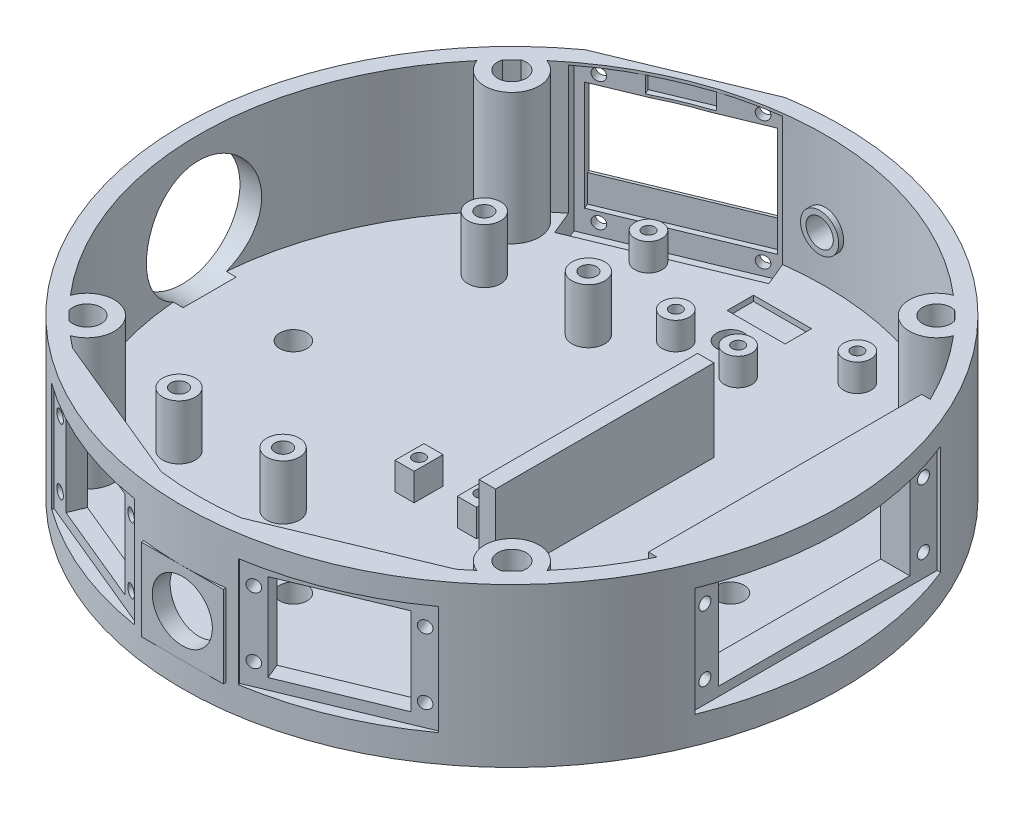
from build123d import *

# Parameters (mm, degrees)
SKETCH1_R                = 60.325
BOSS_EXTRUDE1_DEPTH      = 5
SKETCH3_R                = 60.325
SKETCH3_R_2              = 57.325
BOSS_EXTRUDE3_DEPTH      = 24
BOSS_EXTRUDE13_DEPTH     = 2
SKETCH7_R                = 5.5
CUT_EXTRUDE1_DEPTH       = 5
SKETCH15_R               = 12.5
BOSS_EXTRUDE15_DEPTH     = 3
SKETCH16_R               = 10.55
CUT_EXTRUDE9_DEPTH       = 5
SKETCH17_R               = 2.5000000000000018
SKETCH17_R_2             = 2.500000000000002
SKETCH17_R_3             = 2.5000000000000004
CUT_EXTRUDE10_DEPTH      = 5
SKETCH20_W               = 10.617189631650703
SKETCH20_H               = 4.842928603910877
CUT_EXTRUDE13_DEPTH      = 1
SKETCH26_W               = 50
SKETCH26_H               = 24
BOSS_EXTRUDE46_DEPTH     = 10
SKETCH27_W               = 45
SKETCH27_H               = 20.000000000000004
CUT_EXTRUDE15_DEPTH      = 5
SKETCH29_R               = 1.0999999999999992
CUT_EXTRUDE17_DEPTH      = 10
CUT_EXTRUDE18_DEPTH      = 20
BOSS_EXTRUDE47_DEPTH     = 24
CUT_EXTRUDE19_START      = -30
CUT_EXTRUDE19_DEPTH      = 30
SKETCH31_R               = 3.0000000000000018
SKETCH31_R_2             = 3.0000000000000004
BOSS_EXTRUDE48_DEPTH     = 10
SKETCH32_R               = 1.5000000000000024
SKETCH32_R_2             = 1.5000000000000042
CUT_EXTRUDE20_DEPTH      = 5
SKETCH33_R               = 2.500000000000004
SKETCH33_R_2             = 2.4999999999999973
BOSS_EXTRUDE49_DEPTH     = 5
SKETCH34_R               = 1.100000000000003
SKETCH34_R_2             = 1.100000000000001
SKETCH34_R_3             = 1.1
SKETCH34_R_4             = 1.0999999999999983
CUT_EXTRUDE21_DEPTH      = 5
BOSS_EXTRUDE50_DEPTH     = 15
BOSS_EXTRUDE51_DEPTH     = 2
CUT_EXTRUDE25_DEPTH      = 2
CUT_EXTRUDE26_DEPTH      = 12
SKETCH41_R               = 1.0999999999999992
SKETCH41_R_2             = 1.100000000000001
CUT_EXTRUDE27_DEPTH      = 12
CUT_EXTRUDE28_DEPTH      = 4
CUT_EXTRUDE28_DEPTH_BACK = 2.5
SKETCH44_R               = 2.499999999999999
SKETCH44_R_2             = 2.5000000000000027
BOSS_EXTRUDE52_DEPTH     = 5
SKETCH45_R               = 1.0999999999999983
SKETCH45_R_2             = 1.0999999999999992
CUT_EXTRUDE29_DEPTH      = 5
CUT_EXTRUDE30_DEPTH      = 5
SKETCH47_R               = 1.100000000000001
CUT_EXTRUDE31_DEPTH      = 3
CUT_EXTRUDE32_DEPTH      = 5
SKETCH49_W               = 27
SKETCH49_H               = 5
CUT_EXTRUDE33_DEPTH      = 1
SKETCH52_R               = 3.499999999999999
BOSS_EXTRUDE54_DEPTH     = 4
SKETCH53_R               = 2.500000000000001
CUT_EXTRUDE34_DEPTH      = 4


with BuildPart() as part:
    # Sketch1 → Boss-Extrude1 (new body)
    with BuildSketch(Plane(origin=(0, 0, 0), x_dir=(1, 0, 0), z_dir=(0, 1, 0))):
        Circle(SKETCH1_R)
    extrude(amount=BOSS_EXTRUDE1_DEPTH)

    # Sketch3 → Boss-Extrude3 (add)
    with BuildSketch(Plane(origin=(0, 5, 0), x_dir=(1, 0, 0), z_dir=(0, 1, 0))):
        Circle(SKETCH3_R)
        Circle(SKETCH3_R_2, mode=Mode.SUBTRACT)
    extrude(amount=BOSS_EXTRUDE3_DEPTH)

    # Sketch6 → Boss-Extrude13 (add)
    with BuildSketch(Plane.XY.offset(60.325)):
        Polygon((-7.5, 19.5), (7.5, 19.5), (7.5000000000000036, 4.500000000000001), (-7.4999999999999964, 4.500000000000001), align=None)
    extrude(amount=-BOSS_EXTRUDE13_DEPTH)

    # Sketch7 → Cut-Extrude1 (cut)
    with BuildSketch(Plane.XY.offset(60.325)):
        with Locations((0, 12.313384582393407)):
            Circle(SKETCH7_R)
    extrude(amount=-CUT_EXTRUDE1_DEPTH, mode=Mode.SUBTRACT)

    # Sketch15 → Boss-Extrude15 (add)
    with BuildSketch(Plane.ZY.offset(60.325)):
        with Locations((0, 14.079498945802262)):
            Circle(SKETCH15_R)
    extrude(amount=-BOSS_EXTRUDE15_DEPTH)

    # Sketch16 → Cut-Extrude9 (cut)
    with BuildSketch(Plane.ZY.offset(60.325)):
        with Locations((0, 14.367365331349822)):
            Circle(SKETCH16_R)
    extrude(amount=-CUT_EXTRUDE9_DEPTH, mode=Mode.SUBTRACT)

    # Sketch17 → Cut-Extrude10 (cut)
    with BuildSketch(Plane(origin=(0, 5, 0), x_dir=(1, 0, 0), z_dir=(0, 1, 0))):
        with Locations((0, 40)):
            Circle(SKETCH17_R)
        with Locations((40, 0)):
            Circle(SKETCH17_R_2)
        with Locations((0, -40)):
            Circle(SKETCH17_R_3)
        with Locations((-40, 0)):
            Circle(SKETCH17_R_2)
    extrude(amount=-CUT_EXTRUDE10_DEPTH, mode=Mode.SUBTRACT)

    # Sketch20 → Cut-Extrude13 (cut)
    with BuildSketch(Plane(origin=(0, 5, 0), x_dir=(1, 0, 0), z_dir=(0, 1, 0))):
        with Locations((0.20330529432061706, 46.91179778863133)):
            Rectangle(SKETCH20_W, SKETCH20_H)
    extrude(amount=-CUT_EXTRUDE13_DEPTH, mode=Mode.SUBTRACT)

    # Sketch26 → Boss-Extrude46 (add)
    with BuildSketch(Plane(origin=(50, 0, 0), x_dir=(0, 0, -1), z_dir=(1, 0, 0))):
        with Locations((3.55e-15, 17.000000000000004)):
            Rectangle(SKETCH26_W, SKETCH26_H)
    extrude(amount=BOSS_EXTRUDE46_DEPTH)

    # Sketch27 → Cut-Extrude15 (cut)
    with BuildSketch(Plane(origin=(60.325, 0, 0), x_dir=(0, 0, -1), z_dir=(1, 0, 0))):
        with Locations((7.11e-15, 15.000000000000002)):
            Rectangle(SKETCH27_W, SKETCH27_H)
    extrude(amount=-CUT_EXTRUDE15_DEPTH, mode=Mode.SUBTRACT)

    # Sketch29 → Cut-Extrude17 (cut)
    with BuildSketch(Plane(origin=(55.325, 0, 0), x_dir=(0, 0, -1), z_dir=(1, 0, 0))):
        with Locations((-19.999999999999986, 20.999999999999996)):
            Circle(SKETCH29_R)
        with Locations((-19.999999999999986, 9)):
            Circle(SKETCH29_R)
        with Locations((20.000000000000018, 20.999999999999996)):
            Circle(SKETCH29_R)
        with Locations((20.000000000000014, 9.151874819132662)):
            Circle(SKETCH29_R)
    extrude(amount=-CUT_EXTRUDE17_DEPTH, mode=Mode.SUBTRACT)

    # Sketch28 → Cut-Extrude18 (cut)
    with BuildSketch(Plane(origin=(60.325, 0, 0), x_dir=(0, 0, -1), z_dir=(1, 0, 0))):
        Polygon((-17.499999999999996, 23.348125180867335), (17.500000000000004, 23.348125180867342), (17.500000000000007, 6.6518748191326615), (-17.499999999999996, 6.651874819132655), align=None)
    extrude(amount=-CUT_EXTRUDE18_DEPTH, mode=Mode.SUBTRACT)

    # Sketch5 → Boss-Extrude47 (add)
    with BuildSketch(Plane(origin=(0, 5, 0), x_dir=(1, 0, 0), z_dir=(0, 1, 0))):
        with BuildLine():
            ThreePointArc((-43.60197437500719, 37.21590326192842), (-35.35533905932737, 35.35533905932737), (-37.21590326192842, 43.60197437500719))
            ThreePointArc((-37.21590326192843, 43.60197437500721), (-38.46725117333861, 42.50207303376248), (-39.68610768350217, 41.366272275048786))
            ThreePointArc((-39.68610768350219, 41.366272275048814), (-37.05239533417509, 37.05239533417509), (-41.366272275048814, 39.6861076835022))
            ThreePointArc((-41.36627227504878, 39.686107683502186), (-42.50207303376247, 38.467251173338624), (-43.6019743750072, 37.21590326192844))
        make_face()
        with BuildLine():
            ThreePointArc((37.21590326192817, 43.601974375007195), (35.35533905932738, 35.355339059327385), (43.601974375007124, 37.21590326192848))
            ThreePointArc((43.60197437500715, 37.215903261928496), (42.50207303376246, 38.46725117333864), (41.36627227504882, 39.68610768350214))
            ThreePointArc((41.36627227504881, 39.68610768350213), (37.05239533417504, 37.05239533417516), (39.68610768350197, 41.36627227504895))
            ThreePointArc((39.68610768350199, 41.36627227504897), (38.46725117333843, 42.502073033762635), (37.21590326192824, 43.601974375007366))
        make_face()
        with BuildLine():
            ThreePointArc((-43.601974375007224, -37.2159032619284), (-42.50207303376248, -38.46725117333861), (-41.36627227504879, -39.68610768350217))
            ThreePointArc((-41.36627227504882, -39.68610768350219), (-37.05239533417508, -37.052395334175095), (-39.68610768350219, -41.36627227504882))
            ThreePointArc((-39.686107683502186, -41.36627227504878), (-38.467251173338624, -42.502073033762464), (-37.215903261928425, -43.60197437500721))
            ThreePointArc((-37.2159032619284, -43.6019743750072), (-35.35533905932736, -35.35533905932738), (-43.60197437500719, -37.21590326192841))
        make_face()
        with BuildLine():
            ThreePointArc((43.60197437500762, -37.21590326192784), (35.35533905932785, -35.35533905932691), (37.21590326192878, -43.601974375006684))
            ThreePointArc((37.21590326192883, -43.60197437500686), (38.467251173339065, -42.50207303376207), (39.68610768350268, -41.3662722750483))
            ThreePointArc((39.68610768350273, -41.36627227504833), (37.05239533417553, -37.05239533417466), (41.3662722750493, -39.68610768350171))
            ThreePointArc((41.36627227504923, -39.6861076835017), (42.50207303376294, -38.46725117333809), (43.60197437500768, -37.215903261927885))
        make_face()
    extrude(amount=BOSS_EXTRUDE47_DEPTH)

    # Sketch30 → Cut-Extrude19 (cut)
    with BuildSketch(Plane(origin=(0, 29, 0), x_dir=(1, 0, 0), z_dir=(0, 1, 0)).offset(CUT_EXTRUDE19_START)):
        with BuildLine():
            Line((51.783140736674326, 30.9453059517236), (68.40972028142612, 30.9453059517236))
            ThreePointArc((68.40972028142612, 30.9453059517236), (75.07900376332695, -0.803108545018857), (67.73210824333012, -32.401594132736065))
            Line((67.73210824333012, -32.401594132736065), (50.88459808878757, -32.401594132736065))
            ThreePointArc((50.88459808878757, -32.401594132736065), (60.31893223906523, -0.8555925075975032), (51.783140736674326, 30.9453059517236))
        make_face()
    extrude(amount=CUT_EXTRUDE19_DEPTH, mode=Mode.SUBTRACT)

    # Sketch31 → Boss-Extrude48 (add)
    with BuildSketch(Plane(origin=(0, 5, 0), x_dir=(1, 0, 0), z_dir=(0, 1, 0))):
        with Locations((-33.05, 28)):
            Circle(SKETCH31_R)
        with Locations((-14.000000000000004, 28)):
            Circle(SKETCH31_R_2)
        with Locations((-13.999999999999996, -27.88)):
            Circle(SKETCH31_R_2)
        with Locations((-33.05, -27.88)):
            Circle(SKETCH31_R)
    extrude(amount=BOSS_EXTRUDE48_DEPTH)

    # Sketch32 → Cut-Extrude20 (cut)
    with BuildSketch(Plane(origin=(0, 15, 0), x_dir=(1, 0, 0), z_dir=(0, 1, 0))):
        with Locations((-13.999999999999996, -27.88)):
            Circle(SKETCH32_R)
        with Locations((-33.05, -27.88)):
            Circle(SKETCH32_R_2)
        with Locations((-33.05, 28)):
            Circle(SKETCH32_R_2)
        with Locations((-14.000000000000004, 28)):
            Circle(SKETCH32_R)
    extrude(amount=-CUT_EXTRUDE20_DEPTH, mode=Mode.SUBTRACT)

    # Sketch33 → Boss-Extrude49 (add)
    with BuildSketch(Plane(origin=(0, 5, 0), x_dir=(1, 0, 0), z_dir=(0, 1, 0))):
        with Locations((-5.000000000000004, 35)):
            Circle(SKETCH33_R)
        with Locations((6.3999989036082425, 35.004999773071894)):
            Circle(SKETCH33_R_2)
        Polygon((-6.750000000000009, -14.647089988643435), (-3.2500000000000084, -14.647089988643431), (-3.2500000000000084, -9.352910011356565), (-6.750000000000009, -9.352910011356565), align=None)
        Polygon((4.649999999999994, -14.647089988643435), (8.149999999999995, -14.647089988643435), (8.149999999999993, -9.352910011356565), (4.649999999999994, -9.352910011356565), align=None)
    extrude(amount=BOSS_EXTRUDE49_DEPTH)

    # Sketch34 → Cut-Extrude21 (cut)
    with BuildSketch(Plane(origin=(0, 10, 0), x_dir=(1, 0, 0), z_dir=(0, 1, 0))):
        with Locations((6.3999989036082425, 35.004999773071894)):
            Circle(SKETCH34_R)
        with Locations((6.399998903608244, -12)):
            Circle(SKETCH34_R_2)
        with Locations((-5.000000000000003, -12)):
            Circle(SKETCH34_R_3)
        with Locations((-5.000000000000004, 35)):
            Circle(SKETCH34_R_4)
    extrude(amount=-CUT_EXTRUDE21_DEPTH, mode=Mode.SUBTRACT)

    # Sketch35 → Boss-Extrude50 (add)
    with BuildSketch(Plane(origin=(0, 5, 0), x_dir=(1, 0, 0), z_dir=(0, 1, 0))):
        Polygon((13.999999999999998, 20), (16.999999999999996, 20), (17, -20), (14.000000000000004, -20), align=None)
    extrude(amount=BOSS_EXTRUDE50_DEPTH)

    # Sketch39 → Boss-Extrude51 (add)
    with BuildSketch(Plane(origin=(21.171960895598467, 0, 51.113635136187), x_dir=(0, -1, 0), z_dir=(0.38268343236508734, 0, 0.9238795325112877))):
        Polygon((-29, 15.014391088551141), (-5.000000000000002, 15.014391088551141), (-4.999999999999997, -14.985608911448859), (-29, -14.985608911448859), align=None)
    boss_extrude51 = extrude(amount=BOSS_EXTRUDE51_DEPTH)

    # Sketch37 → Cut-Extrude25 (cut)
    with BuildSketch(Plane(origin=(23.0853780574239, 0, 55.73303279874344), x_dir=(0, -1, 0), z_dir=(0.38268343236508734, 0, 0.9238795325112877))):
        Polygon((-25, 13.999999999999996), (-5.000000000000001, 13.999999999999996), (-4.999999999999999, -14.000000000000004), (-24.999999999999996, -14.000000000000004), align=None)
    cut_extrude25 = extrude(amount=-CUT_EXTRUDE25_DEPTH, mode=Mode.SUBTRACT)

    # Sketch40 → Cut-Extrude26 (cut)
    with BuildSketch(Plane(origin=(23.0853780574239, 0, 55.73303279874344), x_dir=(0, -1, 0), z_dir=(0.38268343236508734, 0, 0.9238795325112877))):
        Polygon((-23, 9.999999999999996), (-7.000000000000003, 9.999999999999996), (-6.999999999999998, -10.000000000000004), (-22.999999999999996, -10.000000000000004), align=None)
    cut_extrude26 = extrude(amount=-CUT_EXTRUDE26_DEPTH, mode=Mode.SUBTRACT)

    # Sketch41 → Cut-Extrude27 (cut)
    with BuildSketch(Plane(origin=(23.0853780574239, 0, 55.73303279874344), x_dir=(0, -1, 0), z_dir=(0.38268343236508734, 0, 0.9238795325112877))):
        with Locations((-21, 12)):
            Circle(SKETCH41_R)
        with Locations((-9.000000000000002, 12)):
            Circle(SKETCH41_R_2)
        with Locations((-8.999999999999998, -12)):
            Circle(SKETCH41_R_2)
        with Locations((-20.999999999999996, -12)):
            Circle(SKETCH41_R)
    cut_extrude27 = extrude(amount=-CUT_EXTRUDE27_DEPTH, mode=Mode.SUBTRACT)

    # Mirror2: Boss-Extrude51, Cut-Extrude25, Cut-Extrude26, Cut-Extrude27 across plane
    add(boss_extrude51.mirror(Plane(origin=(0, 0, 0), x_dir=(0, 0, 1), z_dir=(1, 0, 0))))
    add(cut_extrude25.mirror(Plane(origin=(0, 0, 0), x_dir=(0, 0, 1), z_dir=(1, 0, 0))), mode=Mode.SUBTRACT)
    add(cut_extrude26.mirror(Plane(origin=(0, 0, 0), x_dir=(0, 0, 1), z_dir=(1, 0, 0))), mode=Mode.SUBTRACT)
    add(cut_extrude27.mirror(Plane(origin=(0, 0, 0), x_dir=(0, 0, 1), z_dir=(1, 0, 0))), mode=Mode.SUBTRACT)

    # Sketch43 → Cut-Extrude28 (cut, two sides: drawn at the far end of the back side and taken through both)
    with BuildSketch(Plane(origin=(-20.923216664561146, 0, -50.51311344005465), x_dir=(0, -1, 0), z_dir=(0.38268343236508734, 0, 0.9238795325112877)).offset(-CUT_EXTRUDE28_DEPTH_BACK)):
        Polygon((-28.5, 15), (-1.0000000000000009, 15), (-0.9999999999999974, -15), (-28.499999999999996, -15), align=None)
    extrude(amount=CUT_EXTRUDE28_DEPTH + CUT_EXTRUDE28_DEPTH_BACK, mode=Mode.SUBTRACT)

    # Sketch44 → Boss-Extrude52 (add)
    with BuildSketch(Plane(origin=(0, 5, 0), x_dir=(1, 0, 0), z_dir=(0, 1, 0))):
        with Locations((-20, 45)):
            Circle(SKETCH44_R)
        with Locations((45, -30)):
            Circle(SKETCH44_R_2)
        with Locations((18.229539652623778, 45)):
            Circle(SKETCH44_R)
        with Locations((18.229539652623778, -32.02717202587299)):
            Circle(SKETCH44_R)
    extrude(amount=BOSS_EXTRUDE52_DEPTH)

    # Sketch45 → Cut-Extrude29 (cut)
    with BuildSketch(Plane(origin=(0, 10, 0), x_dir=(1, 0, 0), z_dir=(0, 1, 0))):
        with Locations((-20, 45)):
            Circle(SKETCH45_R)
        with Locations((18.229539652623778, 45)):
            Circle(SKETCH45_R)
        with Locations((18.229539652623778, -32.02717202587299)):
            Circle(SKETCH45_R)
        with Locations((45, -30)):
            Circle(SKETCH45_R_2)
    extrude(amount=-CUT_EXTRUDE29_DEPTH, mode=Mode.SUBTRACT)

    # Sketch46 → Cut-Extrude30 (cut)
    with BuildSketch(Plane(origin=(-21.879925245473853, 0, -52.82281227133289), x_dir=(0.9238795325112877, 0, -0.38268343236508756), z_dir=(0.38268343236508756, 0, 0.9238795325112877))):
        Polygon((-13.50000000000003, 25), (13.49999999999997, 25), (13.499999999999968, 10), (-13.500000000000028, 10), align=None)
    extrude(amount=-CUT_EXTRUDE30_DEPTH, mode=Mode.SUBTRACT)

    # Sketch47 → Cut-Extrude31 (cut)
    with BuildSketch(Plane(origin=(-21.879925245473853, 0, -52.82281227133289), x_dir=(0.9238795325112877, 0, -0.38268343236508756), z_dir=(0.38268343236508756, 0, 0.9238795325112877))):
        with Locations((11.500000000000005, 26.75)):
            Circle(SKETCH47_R)
        with Locations((-11.499999999999995, 26.75)):
            Circle(SKETCH47_R)
        with Locations((-11.5, 3.25)):
            Circle(SKETCH47_R)
        with Locations((11.500000000000002, 3.25)):
            Circle(SKETCH47_R)
    extrude(amount=-CUT_EXTRUDE31_DEPTH, mode=Mode.SUBTRACT)

    # Sketch48 → Cut-Extrude32 (cut)
    with BuildSketch(Plane(origin=(-22.453950394021497, 0, -54.208631570099804), x_dir=(0, -1, 0), z_dir=(0.38268343236508734, 0, 0.9238795325112877))):
        Polygon((-35, 15), (4.999999999999997, 15), (5.000000000000004, -15), (-34.99999999999999, -15), align=None)
    extrude(amount=-CUT_EXTRUDE32_DEPTH, mode=Mode.SUBTRACT)

    # Sketch49 → Cut-Extrude33 (cut)
    with BuildSketch(Plane(origin=(-21.87992524547385, 0, -52.82281227133288), x_dir=(0.9238795325112878, 0, -0.3826834323650871), z_dir=(0.3826834323650871, 0, 0.9238795325112878))):
        Polygon((-5.0000000000000036, 28.45000478430176), (4.9999999999999964, 28.45000478430176), (4.999999999999996, 25.45000478430176), (-5.000000000000003, 25.45000478430176), align=None)
        with Locations((-4.44e-15, 7.5)):
            Rectangle(SKETCH49_W, SKETCH49_H)
    extrude(amount=-CUT_EXTRUDE33_DEPTH, mode=Mode.SUBTRACT)

    # Sketch52 → Boss-Extrude54 (add)
    with BuildSketch(Plane(origin=(0, 0, -60.325), x_dir=(-1, 0, 0), z_dir=(0, 0, -1))):
        with Locations((0, 14)):
            Circle(SKETCH52_R)
    extrude(amount=-BOSS_EXTRUDE54_DEPTH)

    # Sketch53 → Cut-Extrude34 (cut)
    with BuildSketch(Plane(origin=(0, 0, -60.325), x_dir=(-1, 0, 0), z_dir=(0, 0, -1))):
        with Locations((0, 14)):
            Circle(SKETCH53_R)
    extrude(amount=-CUT_EXTRUDE34_DEPTH, mode=Mode.SUBTRACT)


solid = part.part
